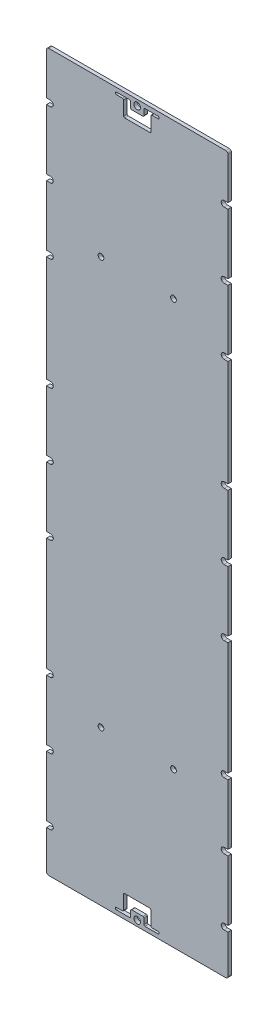
from build123d import *

# Parameters (mm, degrees)
SKETCH3_W                  = 82.8
SKETCH3_H                  = 326.2
SKETCH3_R                  = 0.8
PCB_EXTRUDE_DEPTH          = 1.6
SOLAR_HOLE_SKETCH_R        = 1.5
SOLAR_HOLE_DEPTH           = 2.6
SKETCH4_W                  = 82.8
SKETCH4_H                  = 326.2
SKETCH4_W_2                = 82.5
SKETCH4_H_2                = 325.9
OFFSET_EDGES_DEPTH         = 2.6
CORNER_FILLET_ON_PCB_R     = 1
FILLETS_FOR_SOLAR_HOLE_R   = 0.5
M2_CLEARANCE_HOLE1_D       = 2.6
SKETCH7_W                  = 1.75
SKETCH7_H                  = 2.6
SLOTS_FOR_EDGE_HOLES_DEPTH = 2.6


with BuildPart() as part:
    # Sketch3 → Pcb extrude (new body)
    with BuildSketch(Plane.XY):
        Rectangle(SKETCH3_W, SKETCH3_H)
        with Locations((-39.5, -83.2)):
            Circle(SKETCH3_R, mode=Mode.SUBTRACT)
        with Locations((39.5, -83.2)):
            Circle(SKETCH3_R, mode=Mode.SUBTRACT)
        with Locations((-39.5, 30.8)):
            Circle(SKETCH3_R, mode=Mode.SUBTRACT)
        with Locations((-39.5, 0.8)):
            Circle(SKETCH3_R, mode=Mode.SUBTRACT)
        with Locations((-39.5, -29.2)):
            Circle(SKETCH3_R, mode=Mode.SUBTRACT)
        with Locations((-16.5, -92.7)):
            Circle(SKETCH3_R, mode=Mode.SUBTRACT)
        with Locations((-39.5, -113.2)):
            Circle(SKETCH3_R, mode=Mode.SUBTRACT)
        with Locations((-39.5, -143.2)):
            Circle(SKETCH3_R, mode=Mode.SUBTRACT)
        with Locations((0, -160.4)):
            Circle(SKETCH3_R, mode=Mode.SUBTRACT)
        with Locations((39.5, -143.2)):
            Circle(SKETCH3_R, mode=Mode.SUBTRACT)
        with Locations((39.5, -113.2)):
            Circle(SKETCH3_R, mode=Mode.SUBTRACT)
        with Locations((16.5, -92.7)):
            Circle(SKETCH3_R, mode=Mode.SUBTRACT)
        with Locations((39.5, -29.2)):
            Circle(SKETCH3_R, mode=Mode.SUBTRACT)
        with Locations((39.5, 0.8)):
            Circle(SKETCH3_R, mode=Mode.SUBTRACT)
        with Locations((39.5, 30.8)):
            Circle(SKETCH3_R, mode=Mode.SUBTRACT)
        with Locations((0, 160.4)):
            Circle(SKETCH3_R, mode=Mode.SUBTRACT)
        with Locations((39.5, 141.6)):
            Circle(SKETCH3_R, mode=Mode.SUBTRACT)
        with Locations((-39.5, 141.6)):
            Circle(SKETCH3_R, mode=Mode.SUBTRACT)
        with Locations((16.5, 92.7)):
            Circle(SKETCH3_R, mode=Mode.SUBTRACT)
        with Locations((-16.5, 92.7)):
            Circle(SKETCH3_R, mode=Mode.SUBTRACT)
        with Locations((39.5, 111.6)):
            Circle(SKETCH3_R, mode=Mode.SUBTRACT)
        with Locations((-39.5, 111.6)):
            Circle(SKETCH3_R, mode=Mode.SUBTRACT)
        with Locations((39.5, 81.6)):
            Circle(SKETCH3_R, mode=Mode.SUBTRACT)
        with Locations((-39.5, 81.6)):
            Circle(SKETCH3_R, mode=Mode.SUBTRACT)
    extrude(amount=PCB_EXTRUDE_DEPTH)

    # Solar Hole sketch → Solar Hole (cut, through all)
    with BuildSketch(Plane.XY):
        with Locations((0, 160.4)):
            Circle(SOLAR_HOLE_SKETCH_R)
        with BuildLine():
            Line((-3, 157.6), (3, 157.6))
            Line((3, 157.6), (3, 161.1))
            Line((3, 161.1), (9.5, 161.1))
            ThreePointArc((9.5, 161.1), (10, 160.6), (9.5, 160.1))
            Line((9.5, 160.1), (6.2, 160.1))
            Line((6.2, 160.1), (6.2, 152.8))
            Line((6.2, 152.8), (-6.2, 152.8))
            Line((-6.2, 152.8), (-6.2, 160.1))
            Line((-6.2, 160.1), (-9.5, 160.1))
            ThreePointArc((-9.5, 160.1), (-10, 160.6), (-9.5, 161.1))
            Line((-9.5, 161.1), (-3, 161.1))
            Line((-3, 161.1), (-3, 157.6))
        make_face()
    solar_hole = extrude(amount=SOLAR_HOLE_DEPTH, mode=Mode.SUBTRACT)

    # Mirror Solar Hole: Solar Hole across plane
    add(solar_hole.mirror(Plane.ZX), mode=Mode.SUBTRACT)

    # Sketch4 → offset edges (cut, through all)
    with BuildSketch(Plane.XY):
        Rectangle(SKETCH4_W, SKETCH4_H)
        Rectangle(SKETCH4_W_2, SKETCH4_H_2, mode=Mode.SUBTRACT)
    extrude(amount=OFFSET_EDGES_DEPTH, mode=Mode.SUBTRACT)

    # Corner Fillet on PCB
    corner_fillet_on_pcb_edges = [part.edges().sort_by_distance(p)[0] for p in [
        (-41.25, -162.95, 0.8),
        (-41.25, 162.95, 0.8),
        (41.25, 162.95, 0.8),
        (41.25, -162.95, 0.8),
    ]]
    fillet(corner_fillet_on_pcb_edges, radius=CORNER_FILLET_ON_PCB_R)

    # Fillets for solar hole
    fillets_for_solar_hole_edges = [part.edges().sort_by_distance(p)[0] for p in [
        (3, 161.1, 0.8),
        (3, 157.6, 0.8),
        (-3, 157.6, 0.8),
        (-3, 161.1, 0.8),
        (-6.2, 160.1, 0.8),
        (-6.2, 152.8, 0.8),
        (6.2, 152.8, 0.8),
        (6.2, 160.1, 0.8),
        (6.2, -160.1, 0.8),
        (6.2, -152.8, 0.8),
        (-6.2, -152.8, 0.8),
        (-6.2, -160.1, 0.8),
        (-3, -161.1, 0.8),
        (-3, -157.6, 0.8),
        (3, -157.6, 0.8),
        (3, -161.1, 0.8),
    ]]
    fillet(fillets_for_solar_hole_edges, radius=FILLETS_FOR_SOLAR_HOLE_R)

    # M2 Clearance Hole1 (through all)
    with Locations(Plane(origin=(0, 0, 0), x_dir=(1, 0, 0), z_dir=(0, 0, -1))):
        with Locations((-39.5, 143.2), (-39.5, 113.2), (-39.5, 83.2), (-39.5, 29.2), (-39.5, -0.8), (-39.5, -30.8), (-39.5, -81.6), (-39.5, -111.6), (-39.5, -141.6), (39.5, -141.6), (39.5, -111.6), (16.5, -92.7), (-16.5, -92.7), (39.5, -81.6), (39.5, -30.8), (39.5, -0.8), (39.5, 29.2), (39.5, 83.2), (39.5, 113.2), (39.5, 143.2), (16.5, 92.7), (-16.5, 92.7)):
            Hole(M2_CLEARANCE_HOLE1_D / 2)

    # Sketch7 → Slots for edge holes (cut, through all)
    with BuildSketch(Plane.XY):
        with Locations((-40.375, -29.2)):
            Rectangle(SKETCH7_W, SKETCH7_H)
        with Locations((-40.375, -83.2)):
            Rectangle(SKETCH7_W, SKETCH7_H)
        with Locations((-40.375, -113.2)):
            Rectangle(SKETCH7_W, SKETCH7_H)
        with Locations((-40.375, -143.2)):
            Rectangle(SKETCH7_W, SKETCH7_H)
        with Locations((-40.375, 0.8)):
            Rectangle(SKETCH7_W, SKETCH7_H)
        with Locations((-40.375, 30.8)):
            Rectangle(SKETCH7_W, SKETCH7_H)
        with Locations((-40.375, 81.6)):
            Rectangle(SKETCH7_W, SKETCH7_H)
        with Locations((-40.375, 111.6)):
            Rectangle(SKETCH7_W, SKETCH7_H)
        with Locations((-40.375, 141.6)):
            Rectangle(SKETCH7_W, SKETCH7_H)
        with Locations((40.375, 141.6)):
            Rectangle(SKETCH7_W, SKETCH7_H)
        with Locations((40.375, 111.6)):
            Rectangle(SKETCH7_W, SKETCH7_H)
        with Locations((40.375, 81.6)):
            Rectangle(SKETCH7_W, SKETCH7_H)
        with Locations((40.375, 30.8)):
            Rectangle(SKETCH7_W, SKETCH7_H)
        with Locations((40.375, 0.8)):
            Rectangle(SKETCH7_W, SKETCH7_H)
        with Locations((40.375, -143.2)):
            Rectangle(SKETCH7_W, SKETCH7_H)
        with Locations((40.375, -113.2)):
            Rectangle(SKETCH7_W, SKETCH7_H)
        with Locations((40.375, -29.2)):
            Rectangle(SKETCH7_W, SKETCH7_H)
        with Locations((40.375, -83.2)):
            Rectangle(SKETCH7_W, SKETCH7_H)
    extrude(amount=SLOTS_FOR_EDGE_HOLES_DEPTH, mode=Mode.SUBTRACT)


solid = part.part
